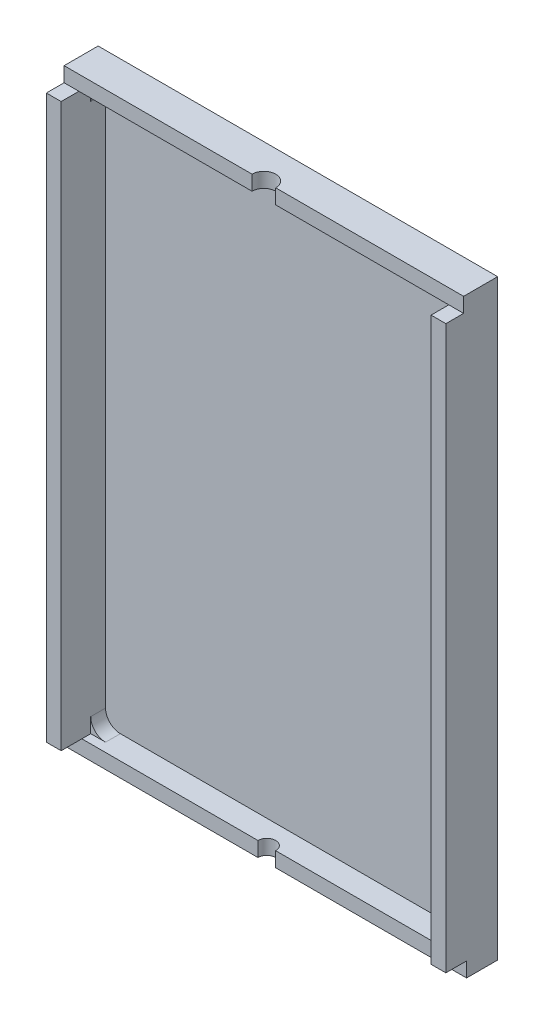
from build123d import *

# Parameters (mm, degrees)
SKETCH_13_W         = 27
SKETCH_13_H         = 40
EXTRUDE_11_DEPTH    = 0.5
SKETCH_14_W         = 27
SKETCH_14_H         = 40
EXTRUDE_14_DEPTH    = 1
SKETCH_17_W         = 27
SKETCH_17_H         = 1
EXTRUDE_15_DEPTH    = 0.8
SKETCH_18_R         = 0.8
CUT_EXTRUDE_4_DEPTH = 2
SKETCH_22_W         = 27
SKETCH_22_H         = 1
EXTRUDE_18_DEPTH    = 0.6
SKETCH_23_R         = 0.6
CUT_EXTRUDE_6_DEPTH = 1
SKETCH_24_W         = 1
SKETCH_24_H         = 38
EXTRUDE_19_DEPTH    = 2
SKETCH_25_W         = 1
SKETCH_25_H         = 38
EXTRUDE_20_DEPTH    = 2


with BuildPart() as part:
    # 草图13 → 凸台-拉伸11 (new body)
    with BuildSketch(Plane.XY):
        with Locations((13.5, 20)):
            Rectangle(SKETCH_13_W, SKETCH_13_H)
    extrude(amount=EXTRUDE_11_DEPTH)

    # 草图14 → 凸台-拉伸14 (add)
    with BuildSketch(Plane.XY.offset(0.5)):
        with Locations((13.5, 20)):
            Rectangle(SKETCH_14_W, SKETCH_14_H)
        with BuildLine():
            Line((2, 1), (25, 1))
            ThreePointArc((25, 1), (25.707106781, 1.292893219), (26, 2))
            Line((26, 2), (26, 38))
            ThreePointArc((26, 38), (25.707106781, 38.707106781), (25, 39))
            Line((25, 39), (2, 39))
            ThreePointArc((2, 39), (1.292893219, 38.707106781), (1, 38))
            Line((1, 38), (1, 2))
            ThreePointArc((1, 2), (1.292893219, 1.292893219), (2, 1))
        make_face(mode=Mode.SUBTRACT)
    extrude(amount=EXTRUDE_14_DEPTH)

    # 草图17 → 凸台-拉伸15 (add)
    with BuildSketch(Plane.XY.offset(1.5)):
        with Locations((13.5, 39.5)):
            Rectangle(SKETCH_17_W, SKETCH_17_H)
    extrude(amount=EXTRUDE_15_DEPTH)

    # 草图18 → 切除-拉伸4 (cut, through all)
    with BuildSketch(Plane.XZ.offset(-39)):
        with Locations((13.5, 2.3)):
            Circle(SKETCH_18_R)
    extrude(amount=-CUT_EXTRUDE_4_DEPTH, mode=Mode.SUBTRACT)

    # 草图22 → 凸台-拉伸18 (add)
    with BuildSketch(Plane.XY.offset(1.5)):
        with Locations((13.5, 0.5)):
            Rectangle(SKETCH_22_W, SKETCH_22_H)
    extrude(amount=EXTRUDE_18_DEPTH)

    # 草图23 → 切除-拉伸6 (cut)
    with BuildSketch(Plane.XZ):
        with Locations((13.5, 2.1)):
            Circle(SKETCH_23_R)
    extrude(amount=-CUT_EXTRUDE_6_DEPTH, mode=Mode.SUBTRACT)

    # 草图24 → 凸台-拉伸19 (add)
    with BuildSketch(Plane.XY.offset(1.5)):
        with Locations((26.5, 20)):
            Rectangle(SKETCH_24_W, SKETCH_24_H)
    extrude(amount=EXTRUDE_19_DEPTH)

    # 草图25 → 凸台-拉伸20 (add)
    with BuildSketch(Plane.XY.offset(1.5)):
        with Locations((0.5, 20)):
            Rectangle(SKETCH_25_W, SKETCH_25_H)
    extrude(amount=EXTRUDE_20_DEPTH)


solid = part.part
